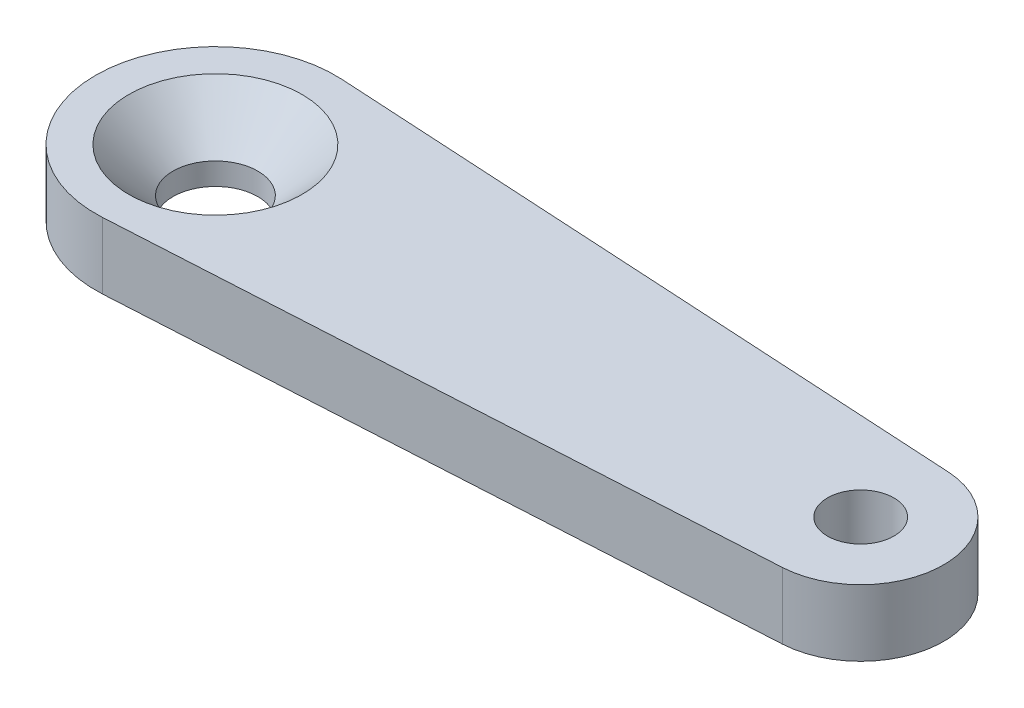
from build123d import *

# Parameters (mm, degrees)
SKETCH_1_R      = 1.15
SKETCH_1_R_2    = 0.9
EXTRUDE_1_DEPTH = 1.8
CHAMFER_1_SIZE  = 1.2


with BuildPart() as part:
    # Эскиз1 → Бобышка-Вытянуть1 (new body)
    with BuildSketch(Plane(origin=(0, 0, 0), x_dir=(1, 0, 0), z_dir=(0, 1, 0))):
        with BuildLine():
            Line((0.185714286, 3.244689539), (17.628571429, 2.246323527))
            ThreePointArc((17.628571429, 2.246323527), (19.75, 0), (17.628571429, -2.246323527))
            Line((17.628571429, -2.246323527), (0.185714286, -3.244689539))
            ThreePointArc((0.185714286, -3.244689539), (-3.25, 0), (0.185714286, 3.244689539))
        make_face()
        Circle(SKETCH_1_R, mode=Mode.SUBTRACT)
        with Locations((17.5, 0)):
            Circle(SKETCH_1_R_2, mode=Mode.SUBTRACT)
    extrude(amount=EXTRUDE_1_DEPTH)

    # Фаска1
    chamfer_1_edges = [part.edges().sort_by_distance(p)[0] for p in [
        (-1.15, 1.8, 0),
    ]]
    chamfer(chamfer_1_edges, length=CHAMFER_1_SIZE)


solid = part.part
